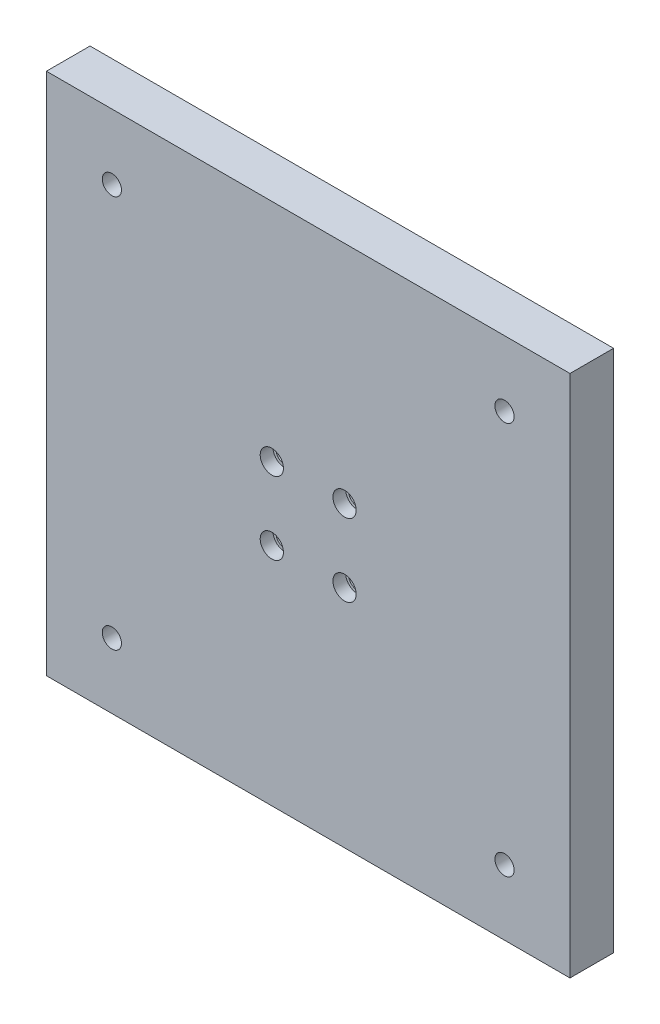
from build123d import *

# Parameters (mm, degrees)
ESQUISSE1_W                                        = 180
ESQUISSE1_H                                        = 180
ESQUISSE1_R                                        = 3
BOSS_EXTRU_1_DEPTH                                 = 15
ESQUISSE6_R                                        = 3
ENL_V_MAT_EXTRU_1_DEPTH                            = 16
CHAMBRAGE_POUR_VIS_T_TE_HEXAGONALE_M41_D           = 4.5
CHAMBRAGE_POUR_VIS_T_TE_HEXAGONALE_M41_CBORE_D     = 8
CHAMBRAGE_POUR_VIS_T_TE_HEXAGONALE_M41_CBORE_DEPTH = 4.4
CHAMBRAGE_POUR_VIS_T_TE_HEXAGONALE_M62_D           = 6.6
CHAMBRAGE_POUR_VIS_T_TE_HEXAGONALE_M62_CBORE_D     = 11
CHAMBRAGE_POUR_VIS_T_TE_HEXAGONALE_M62_CBORE_DEPTH = 6.4


with BuildPart() as part:
    # Esquisse1 → Boss.-Extru.1 (new body)
    with BuildSketch(Plane.XY):
        with Locations((-90, 90)):
            Rectangle(ESQUISSE1_W, ESQUISSE1_H)
        with Locations((-22.5, 22.5)):
            Circle(ESQUISSE1_R, mode=Mode.SUBTRACT)
        with Locations((-157.5, 22.5)):
            Circle(ESQUISSE1_R, mode=Mode.SUBTRACT)
        with Locations((-157.5, 157.5)):
            Circle(ESQUISSE1_R, mode=Mode.SUBTRACT)
        with Locations((-22.5, 157.5)):
            Circle(ESQUISSE1_R, mode=Mode.SUBTRACT)
    extrude(amount=BOSS_EXTRU_1_DEPTH)

    # Esquisse6 → Enlèv. mat.-Extru.1 (cut, through all)
    with BuildSketch(Plane.XY.offset(15)):
        with Locations((-102.5, 77.5)):
            Circle(ESQUISSE6_R)
        with Locations((-77.5, 77.5)):
            Circle(ESQUISSE6_R)
        with Locations((-77.5, 102.5)):
            Circle(ESQUISSE6_R)
        with Locations((-102.5, 102.5)):
            Circle(ESQUISSE6_R)
    extrude(amount=-ENL_V_MAT_EXTRU_1_DEPTH, mode=Mode.SUBTRACT)

    # Chambrage pour vis à tête hexagonale M41 (through all)
    with Locations(Plane.XY.offset(15)):
        with Locations((-102.5, 77.5), (-102.5, 102.5), (-77.5, 102.5), (-77.5, 77.5)):
            CounterBoreHole(CHAMBRAGE_POUR_VIS_T_TE_HEXAGONALE_M41_D / 2, CHAMBRAGE_POUR_VIS_T_TE_HEXAGONALE_M41_CBORE_D / 2, CHAMBRAGE_POUR_VIS_T_TE_HEXAGONALE_M41_CBORE_DEPTH)

    # Chambrage pour vis à tête hexagonale M62 (through all)
    with Locations(Plane(origin=(0, 0, 0), x_dir=(-1, 0, 0), z_dir=(0, 0, -1))):
        with Locations((157.5, 22.5), (22.5, 22.5), (22.5, 157.5), (157.5, 157.5)):
            CounterBoreHole(CHAMBRAGE_POUR_VIS_T_TE_HEXAGONALE_M62_D / 2, CHAMBRAGE_POUR_VIS_T_TE_HEXAGONALE_M62_CBORE_D / 2, CHAMBRAGE_POUR_VIS_T_TE_HEXAGONALE_M62_CBORE_DEPTH)


solid = part.part
